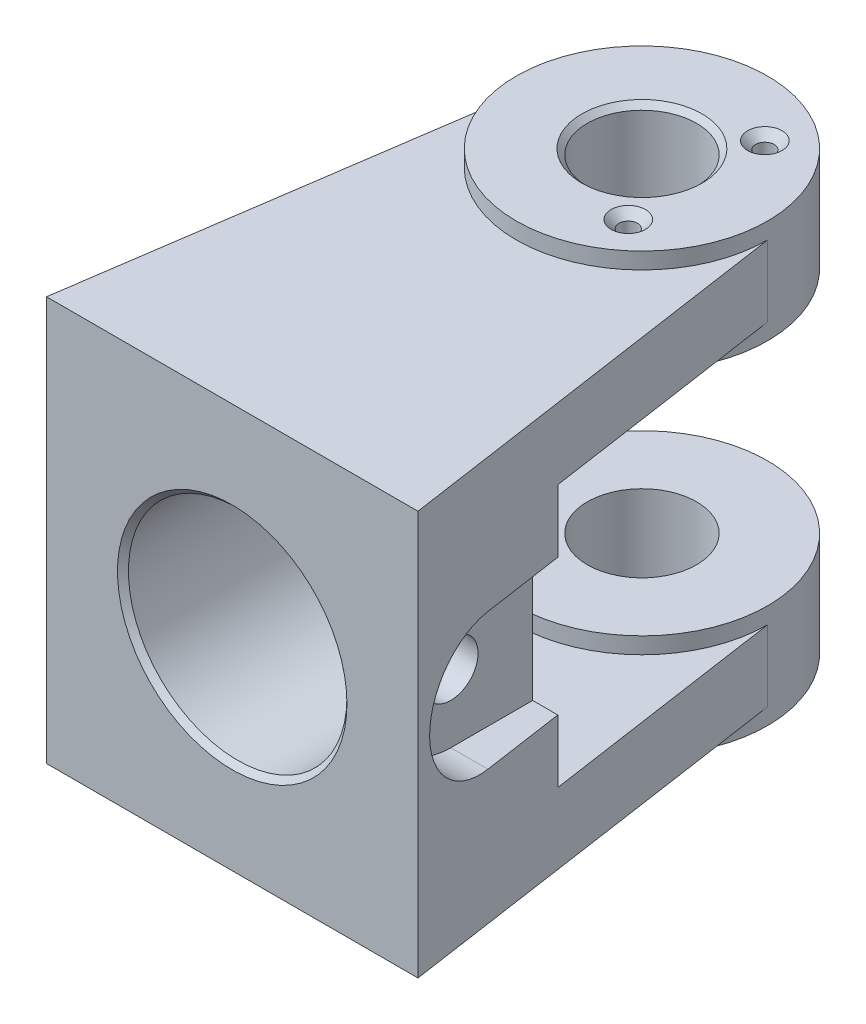
from build123d import *

# Parameters (mm, degrees)
BOSS_EXTRUDE2_DEPTH                          = 6.5
SKETCH2_R                                    = 23
SKETCH2_R_2                                  = 10
BOSS_EXTRUDE3_DEPTH                          = 9.5
BOSS_EXTRUDE4_DEPTH                          = 24
CHAMFER2_SIZE                                = 1
CSK_FOR_M3_COUNTERSUNK_RAISED_HEAD_S_2_COUNT = 2
CSK_FOR_M3_COUNTERSUNK_RAISED_HEAD_S_2_PITCH = 25
CHAMFER2_OF_MIRROR4_SIZE                     = 1
SKETCH4_R                                    = 20
CUT_EXTRUDE1_DEPTH                           = 126.420293414
CUT_EXTRUDE2_DEPTH                           = 9
CUT_EXTRUDE3_REACH                           = 125.366
CUT_EXTRUDE3_END_RADIUS                      = 20
SKETCH6_5_R                                  = 5
CHAMFER3_SIZE                                = 1


with BuildPart() as part:
    # Sketch1 → Boss-Extrude2 (new, symmetric)
    with BuildSketch(Plane(origin=(0, 0, 0), x_dir=(1, 0, 0), z_dir=(0, 1, 0))):
        with BuildLine():
            ThreePointArc((-23, 0), (0, -23), (23, 0))
            Line((23, 0), (34, -75))
            Line((34, -75), (-34, -75))
            Line((-34, -75), (-23, 0))
        make_face()
    boss_extrude2 = extrude(amount=BOSS_EXTRUDE2_DEPTH, both=True)

    # Sketch2 → Boss-Extrude3 (add, symmetric)
    with BuildSketch(Plane(origin=(0, 0, 0), x_dir=(1, 0, 0), z_dir=(0, 1, 0))):
        with Locations(Location((0, 0, 0), (0, 0, 270))):
            Circle(SKETCH2_R)
        with Locations(Location((0, 0, 0), (0, 0, 270))):
            Circle(SKETCH2_R_2, mode=Mode.SUBTRACT)
    boss_extrude3 = extrude(amount=BOSS_EXTRUDE3_DEPTH, both=True)

    # Sketch3 → Boss-Extrude4 (add)
    with BuildSketch(Plane(origin=(0, 6.5, 0), x_dir=(1, 0, 0), z_dir=(0, 1, 0))):
        Polygon((-29.6, -45), (29.6, -45), (34, -75), (-34, -75), align=None)
    boss_extrude4 = extrude(amount=BOSS_EXTRUDE4_DEPTH)

    # Chamfer2
    chamfer2_edges = [part.edges().sort_by_distance(p)[0] for p in [
        (0, -9.5, -10),
    ]]
    chamfer(chamfer2_edges, length=CHAMFER2_SIZE)

    # Sketch12 → CSK for M3 Countersunk Raised Head Screw (revolve, cut)
    with BuildSketch(Plane(origin=(10, -9.5, -12.5), x_dir=(0, 0, -1), z_dir=(1, 0, 0))):
        Polygon((0, 0), (0, 12), (1.7, 10.978536948), (1.7, 1.45), (3.15, 0), align=None)
    csk_for_m3_countersunk_raised_head_screw = revolve(axis=Axis((10, -15.85, -12.5), (0, 1, 0)), mode=Mode.SUBTRACT)

    # CSK for M3 Countersunk Raised Head S 2: CSK for M3 Countersunk Raised Head Screw ×2
    with Locations(*[(0, 0, i * CSK_FOR_M3_COUNTERSUNK_RAISED_HEAD_S_2_PITCH) for i in range(1, CSK_FOR_M3_COUNTERSUNK_RAISED_HEAD_S_2_COUNT)]):
        add(csk_for_m3_countersunk_raised_head_screw, mode=Mode.SUBTRACT)

    # Mirror4: Boss-Extrude2, Boss-Extrude3, Boss-Extrude4, CSK for M3 Countersunk Raised Head Screw across plane
    add(boss_extrude2.mirror(Plane.ZX.offset(30.5)))
    add(boss_extrude3.mirror(Plane.ZX.offset(30.5)))
    add(boss_extrude4.mirror(Plane.ZX.offset(30.5)))
    add(csk_for_m3_countersunk_raised_head_screw.mirror(Plane.ZX.offset(30.5)), mode=Mode.SUBTRACT)

    # Mirror4 copy 1 sketch → Mirror4 copy 1 (revolve, cut)
    with BuildSketch(Plane(origin=(10, 70.5, 12.5), x_dir=(0, 0, -1), z_dir=(1, 0, 0))):
        Polygon((0, 0), (0, -12), (1.7, -10.978536948), (1.7, -1.45), (3.15, 0), align=None)
    revolve(axis=Axis((10, 76.85, 12.5), (0, 1, 0)), mode=Mode.SUBTRACT)

    # Chamfer2 of Mirror4
    chamfer2_of_mirror4_edges = [part.edges().sort_by_distance(p)[0] for p in [
        (0, 70.5, -10),
    ]]
    chamfer(chamfer2_of_mirror4_edges, length=CHAMFER2_OF_MIRROR4_SIZE)

    # Sketch4 → Cut-Extrude1 (cut, through all)
    with BuildSketch(Plane.XY.offset(75)):
        with Locations((0, 30.5)):
            Circle(SKETCH4_R)
    extrude(amount=-CUT_EXTRUDE1_DEPTH, mode=Mode.SUBTRACT)

    # Sketch6 → Cut-Extrude2 (cut)
    with BuildSketch(Plane(origin=(34, 0, 0), x_dir=(0, 0, -1), z_dir=(1, 0, 0))):
        with BuildLine():
            Line((-60, 43), (-45, 43))
            Line((-45, 43), (-45, 18))
            Line((-45, 18), (-60, 18))
            ThreePointArc((-60, 18), (-72.5, 30.5), (-60, 43))
        make_face()
    extrude(amount=-CUT_EXTRUDE2_DEPTH, mode=Mode.SUBTRACT)

    # Cut-Extrude3: up to this cylinder (the profile starts outside it)
    cut_extrude3_end = Plane(origin=(0, 30.5, 60), z_dir=(0, 0, 1)) * Cylinder(CUT_EXTRUDE3_END_RADIUS, 291.732, mode=Mode.PRIVATE)
    # Sketch6_5 → Cut-Extrude3 (cut, up to the surface)
    with BuildSketch(Plane(origin=(34, 0, 0), x_dir=(0, 0, -1), z_dir=(1, 0, 0)), mode=Mode.PRIVATE) as cut_extrude3_sk1:
        with Locations((-60, 30.5)):
            Circle(SKETCH6_5_R)
    cut_extrude3_tool1 = extrude(cut_extrude3_sk1.sketch, amount=-CUT_EXTRUDE3_REACH, mode=Mode.PRIVATE) - cut_extrude3_end
    add(cut_extrude3_tool1.solids().sort_by_distance((34, 30.5, 60))[0], mode=Mode.SUBTRACT)

    # Chamfer3
    chamfer3_edges = [part.edges().sort_by_distance(p)[0] for p in [
        (-20, 30.5, 75),
    ]]
    chamfer(chamfer3_edges, length=CHAMFER3_SIZE)


solid = part.part
